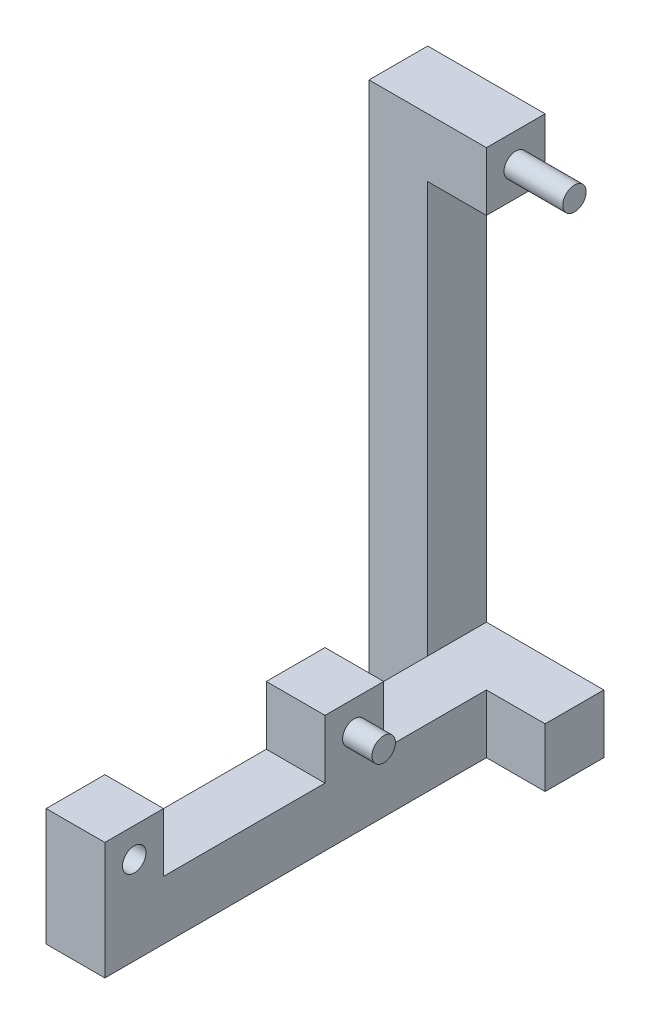
from build123d import *

# Parameters (mm, degrees)
LOWERBASE_W             = 200
LOWERBASE_H             = 200
BOSS_EXTRUDE1_DEPTH     = 200
UPPERBASE_W             = 200
UPPERBASE_H             = 1800
BOSS_EXTRUDE2_DEPTH     = 200
TOPPIVOT_W              = 200
TOPPIVOT_H              = 200
BOSS_EXTRUDE3_DEPTH     = 200
PRESSTABLE_W            = 200
PRESSTABLE_H            = 200
BOSS_EXTRUDE4_DEPTH     = 400
MIDDLERIVET_R           = 40
BOSS_EXTRUDE5_DEPTH     = 300
TOPRIVET_R              = 40
BOSS_EXTRUDE6_DEPTH     = 400
SKETCH6_R               = 40
CUT_EXTRUDE1_DEPTH      = 401
CUT_EXTRUDE1_DEPTH_BACK = 201


with BuildPart() as part:
    # LowerBase → Boss-Extrude1 (new body)
    with BuildSketch(Plane(origin=(0, 0, 0), x_dir=(0, 0, -1), z_dir=(1, 0, 0))):
        Polygon((-1500, 0), (0, 0), (0, 200), (-550, 200), (-750, 200), (-1300, 200), (-1500, 200), align=None)
        with Locations((-1400, 300)):
            Rectangle(LOWERBASE_W, LOWERBASE_H)
        with Locations((-650, 300)):
            Rectangle(LOWERBASE_W, LOWERBASE_H)
    extrude(amount=BOSS_EXTRUDE1_DEPTH)

    # UpperBase → Boss-Extrude2 (add)
    with BuildSketch(Plane(origin=(0, 0, 0), x_dir=(0, 0, -1), z_dir=(1, 0, 0))):
        with Locations((-100, 900)):
            Rectangle(UPPERBASE_W, UPPERBASE_H)
    extrude(amount=-BOSS_EXTRUDE2_DEPTH)

    # TopPivot → Boss-Extrude3 (add)
    with BuildSketch(Plane(origin=(0, 0, 0), x_dir=(0, 0, -1), z_dir=(1, 0, 0))):
        with Locations((-100, 1700)):
            Rectangle(TOPPIVOT_W, TOPPIVOT_H)
    extrude(amount=BOSS_EXTRUDE3_DEPTH)

    # PressTable → Boss-Extrude4 (add)
    with BuildSketch(Plane(origin=(0, 0, 0), x_dir=(0, 0, -1), z_dir=(1, 0, 0))):
        with Locations((-100, 100)):
            Rectangle(PRESSTABLE_W, PRESSTABLE_H)
    extrude(amount=BOSS_EXTRUDE4_DEPTH)

    # MiddleRivet → Boss-Extrude5 (add)
    with BuildSketch(Plane(origin=(0, 0, 0), x_dir=(0, 0, -1), z_dir=(1, 0, 0))):
        with Locations((-650, 300)):
            Circle(MIDDLERIVET_R)
    extrude(amount=BOSS_EXTRUDE5_DEPTH)

    # Sketch6 → Cut-Extrude1 (cut, two sides)
    with BuildSketch(Plane(origin=(0, 0, 0), x_dir=(0, 0, -1), z_dir=(1, 0, 0))) as cut_extrude1_sk:
        with Locations((-1400, 300)):
            Circle(SKETCH6_R)
    extrude(amount=CUT_EXTRUDE1_DEPTH, mode=Mode.SUBTRACT)
    extrude(cut_extrude1_sk.sketch, amount=-CUT_EXTRUDE1_DEPTH_BACK, mode=Mode.SUBTRACT)


with BuildPart() as body_2:
    # TopRivet → Boss-Extrude6 (new body)
    with BuildSketch(Plane(origin=(0, 0, 0), x_dir=(0, 0, -1), z_dir=(1, 0, 0))):
        with Locations((-100, 1700)):
            Circle(TOPRIVET_R)
    extrude(amount=BOSS_EXTRUDE6_DEPTH)


solid = Compound([part.part, body_2.part])
